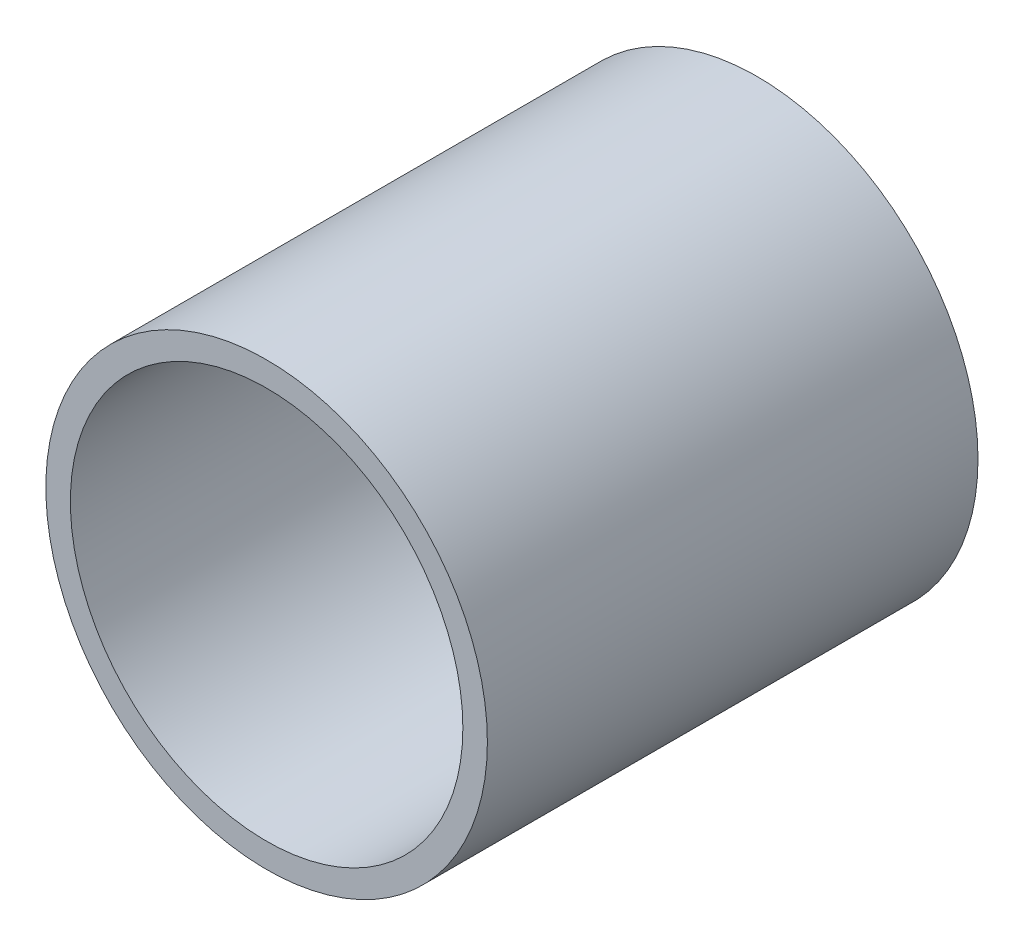
from build123d import *

# Parameters (mm, degrees)
SKETCH1_R      = 28.575
SKETCH1_R_2    = 25.4
EXTRUDE1_DEPTH = 31.75


with BuildPart() as part:
    # Sketch1 → Extrude1 (new body, symmetric)
    with BuildSketch(Plane.XY):
        Circle(SKETCH1_R)
        Circle(SKETCH1_R_2, mode=Mode.SUBTRACT)
    extrude(amount=EXTRUDE1_DEPTH, both=True)


solid = part.part
